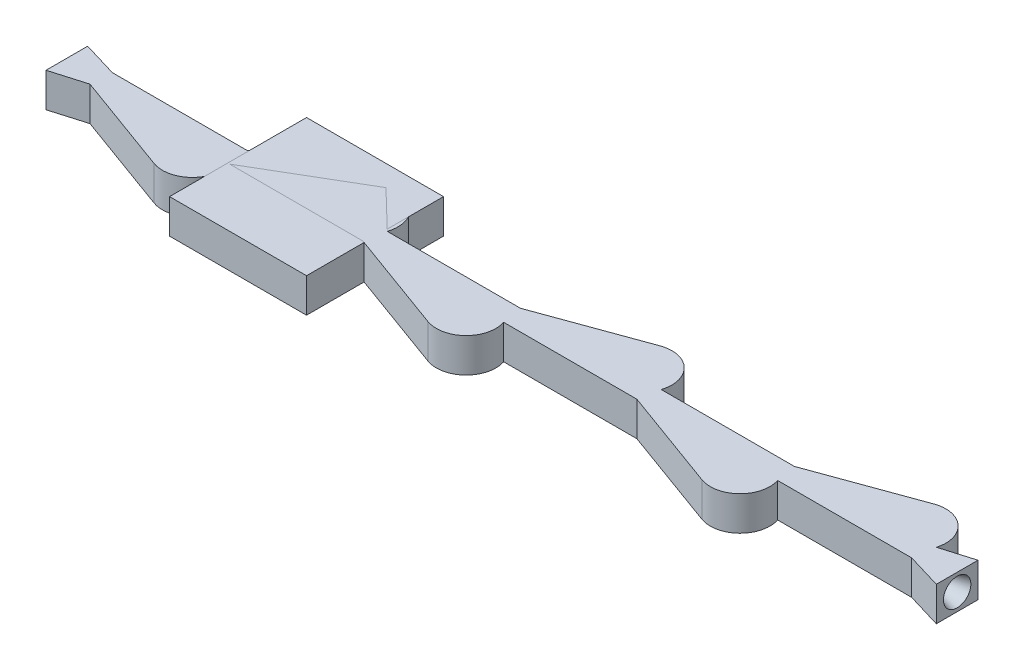
from build123d import *

# Parameters (mm, degrees)
SKETCH3_W               = 20
SKETCH3_H               = 20
BOSS_EXTRUDE2_DEPTH     = 2.5
CUT_EXTRUDE_THIN2_DEPTH = 0.5
CUT_EXTRUDE_THIN4_DEPTH = 0.5
LPATTERN1_COUNT         = 2
LPATTERN1_PITCH         = 20
LPATTERN2_COUNT         = 3
LPATTERN2_PITCH         = 40
SKETCH7_W               = 20
SKETCH7_H               = 5
BOSS_EXTRUDE3_DEPTH     = 5
SKETCH9_W               = 130
SKETCH9_H               = 20
CUT_EXTRUDE1_DEPTH      = 1
CUT_EXTRUDE1_DEPTH_BACK = 6


with BuildPart() as part:
    # Sketch3 → Boss-Extrude2 (new body, symmetric)
    with BuildSketch(Plane(origin=(0, 0, 0), x_dir=(1, 0, 0), z_dir=(0, 1, 0))):
        Rectangle(SKETCH3_W, SKETCH3_H)
    extrude(amount=BOSS_EXTRUDE2_DEPTH, both=True)

    # Sketch6 → Cut-Extrude-Thin2 (cut, symmetric)
    with BuildSketch(Plane(origin=(0, 0, 0), x_dir=(1, 0, 0), z_dir=(0, 1, 0))):
        Polygon((-10, -0.5), (0, -0.5), (10, -0.5), (10, 0.5), (0, 0.5), (-10, 0.5), align=None)
    extrude(amount=CUT_EXTRUDE_THIN2_DEPTH, both=True, mode=Mode.SUBTRACT)

    # Sketch4 → Cut-Extrude-Thin4 (cut, symmetric)
    with BuildSketch(Plane(origin=(0, 0, 0), x_dir=(1, 0, 0), z_dir=(0, 1, 0))):
        with BuildLine():
            Line((-10.171010072, -0.46984631), (5.006878464, -5.994145956))
            ThreePointArc((5.006878464, -5.994145956), (9.449135926, -3.429407415), (6.151971613, 0.5))
            Line((6.151971613, 0.5), (6.151971613, -0.5))
            ThreePointArc((6.151971613, -0.5), (8.464328173, -3.255759238), (5.348898608, -5.054453336))
            Line((5.348898608, -5.054453336), (-9.828989928, 0.46984631))
            Line((-9.828989928, 0.46984631), (-10.171010072, -0.46984631))
        make_face()
    extrude(amount=CUT_EXTRUDE_THIN4_DEPTH, both=True, mode=Mode.SUBTRACT)


with BuildPart() as lpattern1_1:
    # LPattern1: pattern copy
    add(part.part.moved(Location(Vector(1, 0, 0) * (1 * LPATTERN1_PITCH))))


with BuildPart() as body_3:
    # Mirror1: mirrored copy
    add(lpattern1_1.part.mirror(Plane.XY))


with BuildPart() as part_1:
    add(part.part)

    # Combine1: union body 3
    add(body_3.part)


with BuildPart() as lpattern2_1:
    # LPattern2: pattern copy
    add(part_1.part.moved(Location(Vector(1, 0, 0) * (1 * LPATTERN2_PITCH))))


with BuildPart() as lpattern2_2:
    # LPattern2: pattern copy
    add(part_1.part.moved(Location(Vector(1, 0, 0) * (2 * LPATTERN2_PITCH))))


with BuildPart() as part_2:
    add(part_1.part)

    # Combine2: union LPattern2_1, LPattern2_2
    add(lpattern2_1.part)
    add(lpattern2_2.part)


with BuildPart() as body_3_2:
    # Sketch7 → Boss-Extrude3 (new body)
    with BuildSketch(Plane.ZY.offset(10)):
        Rectangle(SKETCH7_W, SKETCH7_H)
    extrude(amount=BOSS_EXTRUDE3_DEPTH)


with BuildPart() as cut_revolve2_tool:
    # Sketch8 → Cut-Revolve2 (revolve)
    with BuildSketch(Plane(origin=(0, 0, 0), x_dir=(1, 0, 0), z_dir=(0, 1, 0))):
        Polygon((-8.187598414, 0), (-15, 0), (-15, -2), align=None)
    revolve(axis=Axis((-8.187598414, 0, 0), (-1, 0, 0)))


with BuildPart() as part_3:
    add(part_2.part)

    # Cut-Revolve2: cut by cut_revolve2_tool
    add(cut_revolve2_tool.part, mode=Mode.SUBTRACT)


with BuildPart() as body_3_2_1:
    add(body_3_2.part)

    # Cut-Revolve2: cut by cut_revolve2_tool
    add(cut_revolve2_tool.part, mode=Mode.SUBTRACT)


with BuildPart() as body_4:
    # Mirror2: mirrored copy
    add(body_3_2_1.part.mirror(Plane.ZY.offset(-50)))


with BuildPart() as body_3_2_2:
    add(body_3_2_1.part)

    # Combine3: union part, body 4
    add(part_3.part)
    add(body_4.part)

    # Sketch9 → Cut-Extrude1 (cut, two sides)
    with BuildSketch(Plane(origin=(0, 2.5, 0), x_dir=(1, 0, 0), z_dir=(0, 1, 0))) as cut_extrude1_sk:
        with Locations((50, 0)):
            Rectangle(SKETCH9_W, SKETCH9_H)
        with BuildLine():
            Line((104.664858321, 6.933838577), (89.735509529, 1.5))
            Line((89.735509529, 1.5), (70.285755633, 1.5))
            ThreePointArc((70.285755633, 1.5), (69.174034965, 5.974125626), (64.664858321, 6.933838577))
            Line((64.664858321, 6.933838577), (49.735509529, 1.5))
            Line((49.735509529, 1.5), (30.285755633, 1.5))
            ThreePointArc((30.285755633, 1.5), (29.174034965, 5.974125626), (24.664858321, 6.933838577))
            Line((24.664858321, 6.933838577), (9.735509529, 1.5))
            Line((9.735509529, 1.5), (-9.853231164, 1.5))
            Line((-9.853231164, 1.5), (-16, 3.344030651))
            Line((-16, 3.344030651), (-16, -3.335786867))
            Line((-16, -3.335786867), (-10.03341654, -1.584104033))
            Line((-10.03341654, -1.584104033), (4.664858321, -6.933838577))
            ThreePointArc((4.664858321, -6.933838577), (9.174034965, -5.974125626), (10.285755633, -1.5))
            Line((10.285755633, -1.5), (29.735509529, -1.5))
            Line((29.735509529, -1.5), (44.664858321, -6.933838577))
            ThreePointArc((44.664858321, -6.933838577), (49.174034965, -5.974125626), (50.285755633, -1.5))
            Line((50.285755633, -1.5), (69.735509529, -1.5))
            Line((69.735509529, -1.5), (84.664858321, -6.933838577))
            ThreePointArc((84.664858321, -6.933838577), (89.174034965, -5.974125626), (90.285755633, -1.5))
            Line((90.285755633, -1.5), (109.853231164, -1.5))
            Line((109.853231164, -1.5), (116, -3.344030651))
            Line((116, -3.344030651), (116, 3.344030651))
            Line((116, 3.344030651), (110.329660684, 1.642928856))
            ThreePointArc((110.329660684, 1.642928856), (109.119838006, 6.025624952), (104.664858321, 6.933838577))
        make_face(mode=Mode.SUBTRACT)
    extrude(amount=CUT_EXTRUDE1_DEPTH, mode=Mode.SUBTRACT)
    extrude(cut_extrude1_sk.sketch, amount=-CUT_EXTRUDE1_DEPTH_BACK, mode=Mode.SUBTRACT)


solid = Compound([lpattern1_1.part, body_3_2_2.part])
